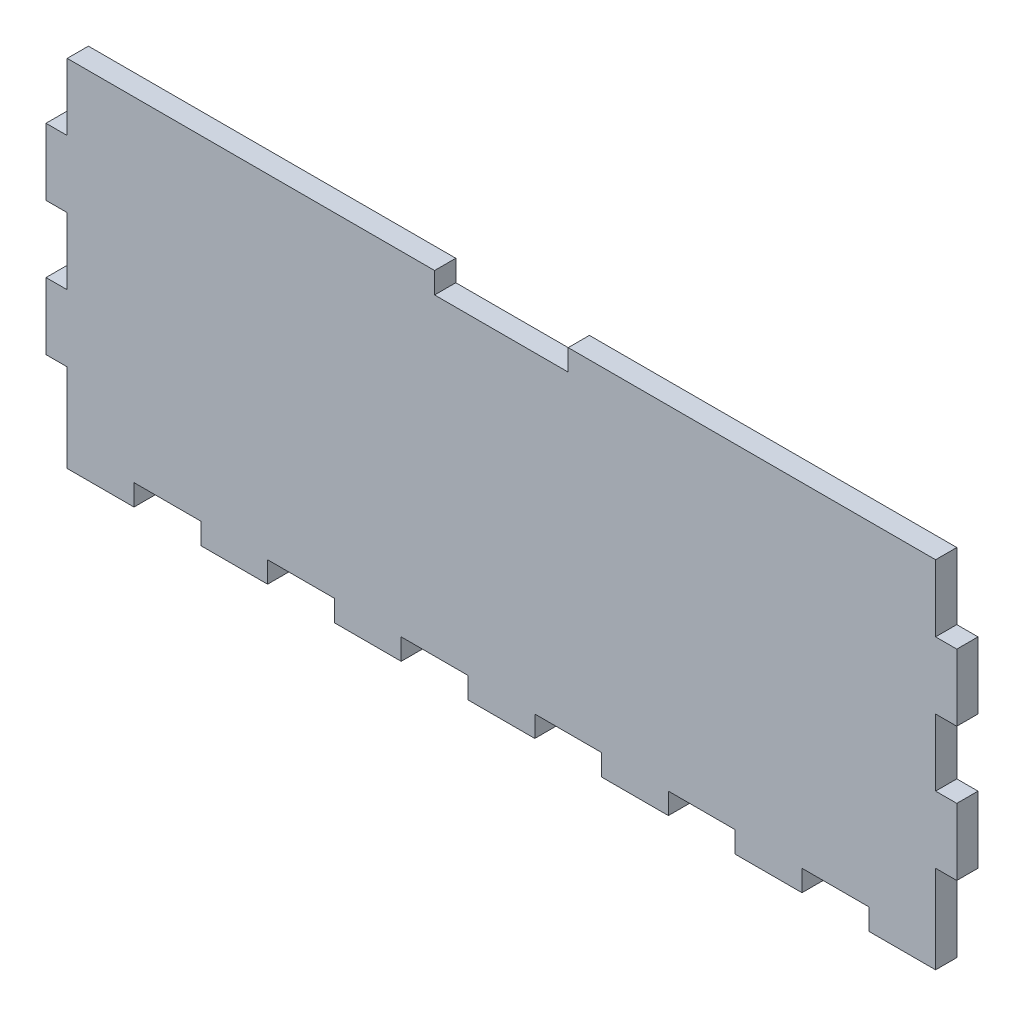
from build123d import *

# Parameters (mm, degrees)
ESQUISSE1_W                = 130
ESQUISSE1_H                = 50
BOSS_EXTRU_1_DEPTH         = 3.175
ESQUISSE2_W                = 3.175
ESQUISSE2_H                = 10
BOSS_EXTRU_2_DEPTH         = 3.175
ESQUISSE3_W                = 20
ESQUISSE3_H                = 3.175
ENL_V_MAT_EXTRU_1_DEPTH    = 3.175
ESQUISSE4_W                = 10
ESQUISSE4_H                = 3.175
BOSS_EXTRU_3_DEPTH         = 3.175
R_P_TITION_LIN_AIRE1_COUNT = 7
R_P_TITION_LIN_AIRE1_PITCH = 20


with BuildPart() as part:
    # Esquisse1 → Boss.-Extru.1 (new body)
    with BuildSketch(Plane.XY):
        with Locations((65, 25)):
            Rectangle(ESQUISSE1_W, ESQUISSE1_H)
    extrude(amount=BOSS_EXTRU_1_DEPTH)

    # Esquisse2 → Boss.-Extru.2 (add)
    with BuildSketch(Plane.XY.offset(3.175)):
        with Locations((131.5875, 35)):
            Rectangle(ESQUISSE2_W, ESQUISSE2_H)
        with Locations((131.5875, 15)):
            Rectangle(ESQUISSE2_W, ESQUISSE2_H)
        with Locations((-1.5875, 35)):
            Rectangle(ESQUISSE2_W, ESQUISSE2_H)
        with Locations((-1.5875, 15)):
            Rectangle(ESQUISSE2_W, ESQUISSE2_H)
    extrude(amount=-BOSS_EXTRU_2_DEPTH)

    # Esquisse3 → Enlèv. mat.-Extru.1 (cut)
    with BuildSketch(Plane.XY.offset(3.175)):
        with Locations((65, 48.4125)):
            Rectangle(ESQUISSE3_W, ESQUISSE3_H)
    extrude(amount=-ENL_V_MAT_EXTRU_1_DEPTH, mode=Mode.SUBTRACT)

    # Esquisse4 → Boss.-Extru.3 (add)
    with BuildSketch(Plane.XY.offset(3.175)):
        with Locations((5, -1.5875)):
            Rectangle(ESQUISSE4_W, ESQUISSE4_H)
    boss_extru_3 = extrude(amount=-BOSS_EXTRU_3_DEPTH)

    # Répétition linéaire1: Boss.-Extru.3 ×7
    with Locations(*[(i * R_P_TITION_LIN_AIRE1_PITCH, 0, 0) for i in range(1, R_P_TITION_LIN_AIRE1_COUNT)]):
        add(boss_extru_3)


solid = part.part
